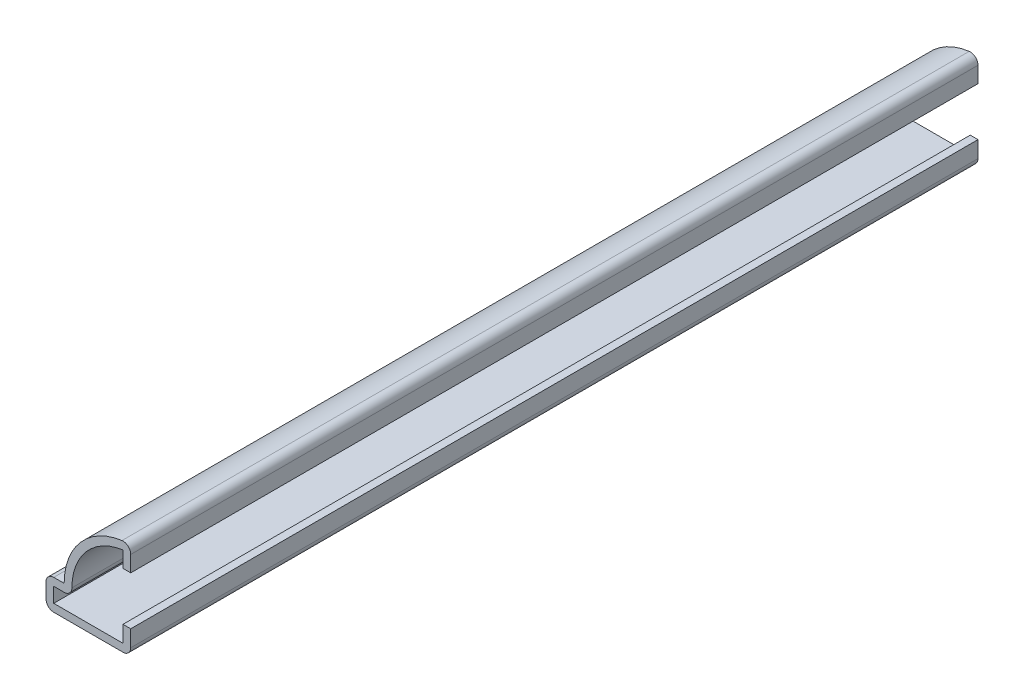
from build123d import *

# Parameters (mm, degrees)
EXTRUDE_THIN1_DEPTH = 111.125
FILLET1_R           = 1.016


with BuildPart() as part:
    # Sketch1 → Extrude-Thin1 (new body)
    with BuildSketch(Plane.XY):
        with BuildLine():
            Line((0, 3.175), (0, 0))
            Line((0, 0), (-11.1125, 0))
            Line((-11.1125, 0), (-11.1125, 3.96875))
            Line((-11.1125, 3.96875), (-8.73125, 3.96875))
            ThreePointArc((-8.73125, 3.96875), (-6.173926083, 10.142676083), (0, 12.7))
            Line((0, 12.7), (0, 9.525))
            Line((0, 9.525), (-1.016, 9.525))
            Line((-1.016, 9.525), (-1.016, 11.616810314))
            ThreePointArc((-1.016, 11.616810314), (-6.1264158, 8.658324821), (-7.648060314, 2.95275))
            Line((-7.648060314, 2.95275), (-10.0965, 2.95275))
            Line((-10.0965, 2.95275), (-10.0965, 1.016))
            Line((-10.0965, 1.016), (-1.016, 1.016))
            Line((-1.016, 1.016), (-1.016, 3.175))
            Line((-1.016, 3.175), (0, 3.175))
        make_face()
    extrude(amount=-EXTRUDE_THIN1_DEPTH)

    # Fillet1
    fillet1_edges = [part.edges().sort_by_distance(p)[0] for p in [
        (-7.648060314, 2.95275, -55.5625),
        (0, 0, -55.5625),
        (-11.1125, 0, -55.5625),
        (-11.1125, 3.96875, -55.5625),
        (0, 12.7, -55.5625),
    ]]
    fillet(fillet1_edges, radius=FILLET1_R)


solid = part.part
